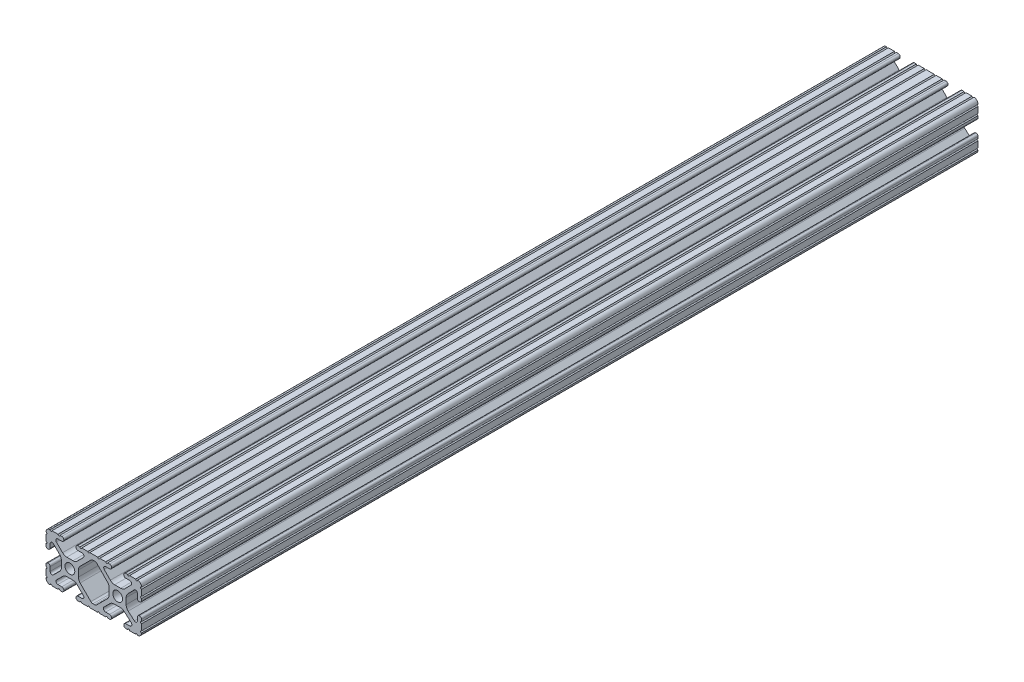
from build123d import *

# Parameters (mm, degrees)
SKETCH1_R      = 2.6035
EXTRUDE1_DEPTH = 444.754


with BuildPart() as part:
    # Sketch1 → Extrude1 (new body)
    with BuildSketch(Plane.XY):
        with BuildLine():
            Line((22.2504, 12.7), (19.03310265, 12.7))
            ThreePointArc((19.03310265, 12.7), (18.52510265, 12.192), (18.01710265, 12.7))
            Line((18.01710265, 12.7), (16.98745015, 12.7))
            ThreePointArc((16.98745015, 12.7), (16.245730386, 12.392769614), (15.9385, 11.65104985))
            Line((15.9385, 11.65104985), (15.9385, 11.53922))
            ThreePointArc((15.9385, 11.53922), (16.245750844, 10.797450844), (16.98752, 10.4902))
            Line((16.98752, 10.4902), (19.116384363, 10.4902))
            ThreePointArc((19.116384363, 10.4902), (20.052502933, 9.869096983), (19.844087081, 8.765172272))
            Line((19.844087081, 8.765172272), (16.618993479, 5.455112286))
            ThreePointArc((16.618993479, 5.455112286), (15.578994274, 4.745442459), (14.344932584, 4.4958))
            Line((14.344932584, 4.4958), (11.083317835, 4.4958))
            ThreePointArc((11.083317835, 4.4958), (9.854330953, 4.743306833), (8.816955189, 5.447238587))
            Line((8.816955189, 5.447238587), (5.564154119, 8.762652677))
            ThreePointArc((5.564154119, 8.762652677), (5.352591412, 9.867473037), (6.289393385, 10.4902))
            Line((6.289393385, 10.4902), (8.41248, 10.4902))
            ThreePointArc((8.41248, 10.4902), (9.154249156, 10.797450844), (9.4615, 11.53922))
            Line((9.4615, 11.53922), (9.4615, 11.65104985))
            ThreePointArc((9.4615, 11.65104985), (9.154269614, 12.392769614), (8.41254985, 12.7))
            Line((8.41254985, 12.7), (7.38288465, 12.7))
            ThreePointArc((7.38288465, 12.7), (6.87488465, 12.192), (6.36688465, 12.7))
            Line((6.36688465, 12.7), (3.14958095, 12.7))
            ThreePointArc((3.14958095, 12.7), (2.64158095, 12.192), (2.13358095, 12.7))
            Line((2.13358095, 12.7), (-2.13358095, 12.7))
            ThreePointArc((-2.13358095, 12.7), (-2.64158095, 12.192), (-3.14958095, 12.7))
            Line((-3.14958095, 12.7), (-6.36689735, 12.7))
            ThreePointArc((-6.36689735, 12.7), (-6.87489735, 12.192), (-7.38289735, 12.7))
            Line((-7.38289735, 12.7), (-8.41254985, 12.7))
            ThreePointArc((-8.41254985, 12.7), (-9.154269614, 12.392769614), (-9.4615, 11.65104985))
            Line((-9.4615, 11.65104985), (-9.4615, 11.53922))
            ThreePointArc((-9.4615, 11.53922), (-9.154249156, 10.797450844), (-8.41248, 10.4902))
            Line((-8.41248, 10.4902), (-6.283641037, 10.4902))
            ThreePointArc((-6.283641037, 10.4902), (-5.297291557, 9.829633109), (-5.532576693, 8.666071843))
            Line((-5.532576693, 8.666071843), (-8.809985098, 5.416263103))
            ThreePointArc((-8.809985098, 5.416263103), (-9.836720513, 4.734920264), (-11.045536121, 4.4958))
            Line((-11.045536121, 4.4958), (-14.354463879, 4.4958))
            ThreePointArc((-14.354463879, 4.4958), (-15.563279487, 4.734920264), (-16.590014902, 5.416263103))
            Line((-16.590014902, 5.416263103), (-19.867423307, 8.666071843))
            ThreePointArc((-19.867423307, 8.666071843), (-20.102708443, 9.829633109), (-19.116358963, 10.4902))
            Line((-19.116358963, 10.4902), (-16.98752, 10.4902))
            ThreePointArc((-16.98752, 10.4902), (-16.245750844, 10.797450844), (-15.9385, 11.53922))
            Line((-15.9385, 11.53922), (-15.9385, 11.65104985))
            ThreePointArc((-15.9385, 11.65104985), (-16.245730386, 12.392769614), (-16.98745015, 12.7))
            Line((-16.98745015, 12.7), (-18.01711535, 12.7))
            ThreePointArc((-18.01711535, 12.7), (-18.52511535, 12.192), (-19.03311535, 12.7))
            Line((-19.03311535, 12.7), (-22.2504, 12.7))
            ThreePointArc((-22.2504, 12.7), (-22.758323491, 12.192000006), (-23.266399977, 12.699846982))
            ThreePointArc((-23.266399977, 12.699846982), (-24.782522516, 12.082522516), (-25.399846982, 10.566399977))
            ThreePointArc((-25.399846982, 10.566399977), (-24.892000006, 10.058323491), (-25.4, 9.5504))
            Line((-25.4, 9.5504), (-25.4, 6.3330836))
            ThreePointArc((-25.4, 6.3330836), (-24.892, 5.8250836), (-25.4, 5.3170836))
            Line((-25.4, 5.3170836), (-25.4, 4.237520184))
            ThreePointArc((-25.4, 4.237520184), (-25.107393763, 3.531106237), (-24.400979816, 3.2385))
            Line((-24.400979816, 3.2385), (-24.23922, 3.2385))
            ThreePointArc((-24.23922, 3.2385), (-23.497450844, 3.545750844), (-23.1902, 4.28752))
            Line((-23.1902, 4.28752), (-23.1902, 6.334741132))
            ThreePointArc((-23.1902, 6.334741132), (-22.556026952, 7.286023527), (-21.434002553, 7.066535717))
            Line((-21.434002553, 7.066535717), (-18.147950853, 3.808156468))
            ThreePointArc((-18.147950853, 3.808156468), (-17.452759693, 2.774838327), (-17.208501877, 1.553619571))
            Line((-17.208501877, 1.553619571), (-17.208501877, -1.695179196))
            ThreePointArc((-17.208501877, -1.695179196), (-17.450738657, -2.911536421), (-18.140486065, -3.942289578))
            Line((-18.140486065, -3.942289578), (-21.431579576, -7.227386226))
            ThreePointArc((-21.431579576, -7.227386226), (-22.55444896, -7.449940594), (-23.1902, -6.498002195))
            Line((-23.1902, -6.498002195), (-23.1902, -4.28752))
            ThreePointArc((-23.1902, -4.28752), (-23.497450844, -3.545750844), (-24.23922, -3.2385))
            Line((-24.23922, -3.2385), (-24.35098, -3.2385))
            ThreePointArc((-24.35098, -3.2385), (-25.092749156, -3.545750844), (-25.4, -4.28752))
            Line((-25.4, -4.28752), (-25.4, -5.3171344))
            ThreePointArc((-25.4, -5.3171344), (-24.892, -5.8251344), (-25.4, -6.3331344))
            Line((-25.4, -6.3331344), (-25.4, -9.5504))
            ThreePointArc((-25.4, -9.5504), (-24.892000006, -10.058323491), (-25.399846982, -10.566399977))
            ThreePointArc((-25.399846982, -10.566399977), (-24.782522516, -12.082522516), (-23.266399977, -12.699846982))
            ThreePointArc((-23.266399977, -12.699846982), (-22.758323491, -12.192000006), (-22.2504, -12.7))
            Line((-22.2504, -12.7), (-19.03308995, -12.7))
            ThreePointArc((-19.03308995, -12.7), (-18.52508995, -12.192), (-18.01708995, -12.7))
            Line((-18.01708995, -12.7), (-16.9874692, -12.7))
            ThreePointArc((-16.9874692, -12.7), (-16.245700044, -12.392749156), (-15.9384492, -11.65098))
            Line((-15.9384492, -11.65098), (-15.9384492, -11.53922))
            ThreePointArc((-15.9384492, -11.53922), (-16.245700044, -10.797450844), (-16.9874692, -10.4902))
            Line((-16.9874692, -10.4902), (-19.116358963, -10.4902))
            ThreePointArc((-19.116358963, -10.4902), (-20.055197748, -9.862578342), (-19.834124023, -8.755124678))
            Line((-19.834124023, -8.755124678), (-16.49660751, -5.423689618))
            ThreePointArc((-16.49660751, -5.423689618), (-15.467274017, -4.736928798), (-14.253591699, -4.4958))
            Line((-14.253591699, -4.4958), (-11.146408301, -4.4958))
            ThreePointArc((-11.146408301, -4.4958), (-9.932725983, -4.736928798), (-8.90339249, -5.423689618))
            Line((-8.90339249, -5.423689618), (-5.565875977, -8.755124678))
            ThreePointArc((-5.565875977, -8.755124678), (-5.344802252, -9.862578342), (-6.283641037, -10.4902))
            Line((-6.283641037, -10.4902), (-8.4125308, -10.4902))
            ThreePointArc((-8.4125308, -10.4902), (-9.154299956, -10.797450844), (-9.4615508, -11.53922))
            Line((-9.4615508, -11.53922), (-9.4615508, -11.65098))
            ThreePointArc((-9.4615508, -11.65098), (-9.154299956, -12.392749156), (-8.4125308, -12.7))
            Line((-8.4125308, -12.7), (-7.38287195, -12.7))
            ThreePointArc((-7.38287195, -12.7), (-6.87487195, -12.192), (-6.36687195, -12.7))
            Line((-6.36687195, -12.7), (-3.14960635, -12.7))
            ThreePointArc((-3.14960635, -12.7), (-2.64160635, -12.192), (-2.13360635, -12.7))
            Line((-2.13360635, -12.7), (2.13360635, -12.7))
            ThreePointArc((2.13360635, -12.7), (2.64159365, -12.1920127), (3.14958095, -12.7))
            Line((3.14958095, -12.7), (6.36691005, -12.7))
            ThreePointArc((6.36691005, -12.7), (6.87491005, -12.192), (7.38291005, -12.7))
            Line((7.38291005, -12.7), (8.4125308, -12.7))
            ThreePointArc((8.4125308, -12.7), (9.154299956, -12.392749156), (9.4615508, -11.65098))
            Line((9.4615508, -11.65098), (9.4615508, -11.53922))
            ThreePointArc((9.4615508, -11.53922), (9.154299956, -10.797450844), (8.4125308, -10.4902))
            Line((8.4125308, -10.4902), (6.289393385, -10.4902))
            ThreePointArc((6.289393385, -10.4902), (5.231590322, -9.783049717), (5.480677245, -8.535265862))
            Line((5.480677245, -8.535265862), (8.597933595, -5.423689618))
            ThreePointArc((8.597933595, -5.423689618), (9.627267088, -4.736928798), (10.840949406, -4.4958))
            Line((10.840949406, -4.4958), (14.102564155, -4.4958))
            ThreePointArc((14.102564155, -4.4958), (15.215927525, -4.697410182), (16.187895372, -5.276636531))
            Line((16.187895372, -5.276636531), (19.868247549, -8.482246082))
            ThreePointArc((19.868247549, -8.482246082), (20.188435806, -9.746879864), (19.116384363, -10.4902))
            Line((19.116384363, -10.4902), (16.9874692, -10.4902))
            ThreePointArc((16.9874692, -10.4902), (16.245700044, -10.797450844), (15.9384492, -11.53922))
            Line((15.9384492, -11.53922), (15.9384492, -11.65098))
            ThreePointArc((15.9384492, -11.65098), (16.245700044, -12.392749156), (16.9874692, -12.7))
            Line((16.9874692, -12.7), (18.01710265, -12.7))
            ThreePointArc((18.01710265, -12.7), (18.52510265, -12.192), (19.03310265, -12.7))
            Line((19.03310265, -12.7), (22.2504, -12.7))
            ThreePointArc((22.2504, -12.7), (22.758323491, -12.192000006), (23.266399977, -12.699846982))
            ThreePointArc((23.266399977, -12.699846982), (24.782522516, -12.082522516), (25.399846982, -10.566399977))
            ThreePointArc((25.399846982, -10.566399977), (24.892000006, -10.058323492), (25.4, -9.550400001))
            Line((25.4, -9.550400001), (25.4, -6.333083592))
            ThreePointArc((25.4, -6.333083592), (24.892000001, -5.825083593), (25.4, -5.317083593))
            Line((25.4, -5.317083593), (25.4, -4.237520184))
            ThreePointArc((25.4, -4.237520184), (25.107393763, -3.531106237), (24.400979816, -3.2385))
            Line((24.400979816, -3.2385), (24.189220184, -3.2385))
            ThreePointArc((24.189220184, -3.2385), (23.482806237, -3.531106237), (23.1902, -4.237520184))
            Line((23.1902, -4.237520184), (23.1902, -6.155876159))
            ThreePointArc((23.1902, -6.155876159), (22.62232736, -7.038258539), (21.583974541, -6.886926384))
            Line((21.583974541, -6.886926384), (18.29817066, -4.024970844))
            ThreePointArc((18.29817066, -4.024970844), (17.493730985, -2.946044689), (17.208501877, -1.630807374))
            Line((17.208501877, -1.630807374), (17.208501877, 1.630807374))
            ThreePointArc((17.208501877, 1.630807374), (17.442348332, 2.82673414), (18.109440981, 3.846495088))
            Line((18.109440981, 3.846495088), (21.526346532, 7.353420386))
            ThreePointArc((21.526346532, 7.353420386), (22.585896263, 7.574939077), (23.1902, 6.676867167))
            Line((23.1902, 6.676867167), (23.1902, 4.237520184))
            ThreePointArc((23.1902, 4.237520184), (23.482806237, 3.531106237), (24.189220184, 3.2385))
            Line((24.189220184, 3.2385), (24.400979816, 3.2385))
            ThreePointArc((24.400979816, 3.2385), (25.107393763, 3.531106237), (25.4, 4.237520184))
            Line((25.4, 4.237520184), (25.4, 5.3170836))
            ThreePointArc((25.4, 5.3170836), (24.891949193, 5.825134407), (25.4, 6.333185215))
            Line((25.4, 6.333185215), (25.4, 9.550400015))
            ThreePointArc((25.4, 9.550400015), (24.892000013, 10.058323498), (25.399846982, 10.566399977))
            ThreePointArc((25.399846982, 10.566399977), (24.782522516, 12.082522516), (23.266399977, 12.699846982))
            ThreePointArc((23.266399977, 12.699846982), (22.758323491, 12.192000006), (22.2504, 12.7))
        make_face()
        with Locations((-12.7, 0)):
            Circle(SKETCH1_R, mode=Mode.SUBTRACT)
        with Locations((12.7, 0)):
            Circle(SKETCH1_R, mode=Mode.SUBTRACT)
        with BuildLine():
            Line((-7.259513935, -3.869413038), (-1.545748891, -9.572766749))
            ThreePointArc((-1.545748891, -9.572766749), (-1.035199478, -9.913400116), (-0.433213048, -10.033))
            Line((-0.433213048, -10.033), (0.433213048, -10.033))
            ThreePointArc((0.433213048, -10.033), (1.035199478, -9.913400116), (1.545748891, -9.572766749))
            Line((1.545748891, -9.572766749), (7.259513935, -3.869413038))
            ThreePointArc((7.259513935, -3.869413038), (7.949261343, -2.838659881), (8.191498123, -1.622302656))
            Line((8.191498123, -1.622302656), (8.191498123, 1.622302656))
            ThreePointArc((8.191498123, 1.622302656), (7.955573352, 2.823327967), (7.282860769, 3.845864069))
            Line((7.282860769, 3.845864069), (1.675572808, 9.561086461))
            ThreePointArc((1.675572808, 9.561086461), (1.161034429, 9.910236611), (0.551456936, 10.033))
            Line((0.551456936, 10.033), (-0.395199982, 10.033))
            ThreePointArc((-0.395199982, 10.033), (-0.994772524, 9.914396349), (-1.50403329, 9.576450301))
            Line((-1.50403329, 9.576450301), (-7.252049147, 3.876839553))
            ThreePointArc((-7.252049147, 3.876839553), (-7.947240307, 2.843521412), (-8.191498123, 1.622302656))
            Line((-8.191498123, 1.622302656), (-8.191498123, -1.622302656))
            ThreePointArc((-8.191498123, -1.622302656), (-7.949261343, -2.838659881), (-7.259513935, -3.869413038))
        make_face(mode=Mode.SUBTRACT)
    extrude(amount=-EXTRUDE1_DEPTH)


solid = part.part
